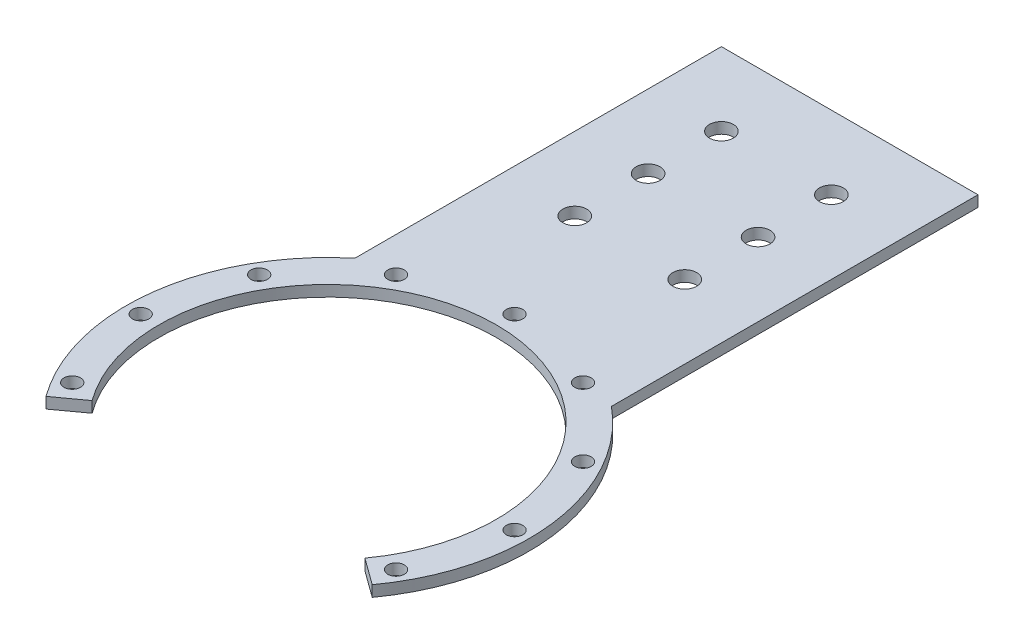
from build123d import *

# Parameters (mm, degrees)
SKETCH1_R               = 55
BOSS_EXTRUDE1_DEPTH     = 3
SKETCH2_W               = 70
SKETCH2_H               = 100
BOSS_EXTRUDE2_DEPTH     = 3
SKETCH4_R               = 46
CUT_EXTRUDE2_DEPTH      = 1
CUT_EXTRUDE2_DEPTH_BACK = 4
CUT_EXTRUDE5_START      = -4
CUT_EXTRUDE5_DEPTH      = 5
CUT_EXTRUDE3_START      = -4
SKETCH5_R               = 2.25
CUT_EXTRUDE3_DEPTH      = 5
CIRPATTERN1_COUNT       = 12
CUT_EXTRUDE4_START      = -4
SKETCH6_R               = 3.25
CUT_EXTRUDE4_DEPTH      = 5
LPATTERN1_COUNT         = 3
LPATTERN1_PITCH         = 20


with BuildPart() as part:
    # Sketch1 → Boss-Extrude1 (new body)
    with BuildSketch(Plane(origin=(0, 0, 0), x_dir=(1, 0, 0), z_dir=(0, 1, 0))):
        Circle(SKETCH1_R)
    extrude(amount=BOSS_EXTRUDE1_DEPTH)

    # Sketch2 → Boss-Extrude2 (add)
    with BuildSketch(Plane(origin=(0, 0, 0), x_dir=(1, 0, 0), z_dir=(0, 1, 0))):
        with Locations((0, 92.426406871)):
            Rectangle(SKETCH2_W, SKETCH2_H)
    extrude(amount=BOSS_EXTRUDE2_DEPTH)

    # Sketch4 → Cut-Extrude2 (cut, two sides)
    with BuildSketch(Plane(origin=(0, 3, 0), x_dir=(1, 0, 0), z_dir=(0, 1, 0))) as cut_extrude2_sk:
        Circle(SKETCH4_R)
    extrude(amount=CUT_EXTRUDE2_DEPTH, mode=Mode.SUBTRACT)
    extrude(cut_extrude2_sk.sketch, amount=-CUT_EXTRUDE2_DEPTH_BACK, mode=Mode.SUBTRACT)

    # Sketch7 → Cut-Extrude5 (cut)
    with BuildSketch(Plane(origin=(0, 3, 0), x_dir=(1, 0, 0), z_dir=(0, 1, 0)).offset(CUT_EXTRUDE5_START)):
        with BuildLine():
            Line((0, 0), (0, -55))
            ThreePointArc((0, -55), (-24.969477486, -49.00535883), (-44.495934691, -32.328188876))
            Line((-44.495934691, -32.328188876), (0, 0))
        make_face()
    cut_extrude5 = extrude(amount=CUT_EXTRUDE5_DEPTH, mode=Mode.SUBTRACT)

    # Mirror1: Cut-Extrude5 across plane
    add(cut_extrude5.mirror(Plane(origin=(0, 0, 0), x_dir=(0, 0, 1), z_dir=(1, 0, 0))), mode=Mode.SUBTRACT)

    # Sketch5 → Cut-Extrude3 (cut)
    with BuildSketch(Plane(origin=(0, 3, 0), x_dir=(1, 0, 0), z_dir=(0, 1, 0)).offset(CUT_EXTRUDE3_START)):
        with Locations((0, 51)):
            Circle(SKETCH5_R)
    cut_extrude3 = extrude(amount=CUT_EXTRUDE3_DEPTH, mode=Mode.SUBTRACT)

    # CirPattern1: Cut-Extrude3 ×12 about axis
    cirpattern1_axis = Axis((0, 0, 0), (0, 1, 0))
    for i in range(1, CIRPATTERN1_COUNT):
        add(cut_extrude3.rotate(cirpattern1_axis, i * 360 / CIRPATTERN1_COUNT), mode=Mode.SUBTRACT)

    # Sketch6 → Cut-Extrude4 (cut)
    with BuildSketch(Plane(origin=(0, 3, 0), x_dir=(1, 0, 0), z_dir=(0, 1, 0)).offset(CUT_EXTRUDE4_START)):
        with Locations((15, 122.426406871)):
            Circle(SKETCH6_R)
        with Locations((-15, 122.426406871)):
            Circle(SKETCH6_R)
    cut_extrude4 = extrude(amount=CUT_EXTRUDE4_DEPTH, mode=Mode.SUBTRACT)

    # LPattern1: Cut-Extrude4 ×3
    with Locations(*[(0, 0, i * LPATTERN1_PITCH) for i in range(1, LPATTERN1_COUNT)]):
        add(cut_extrude4, mode=Mode.SUBTRACT)


solid = part.part
